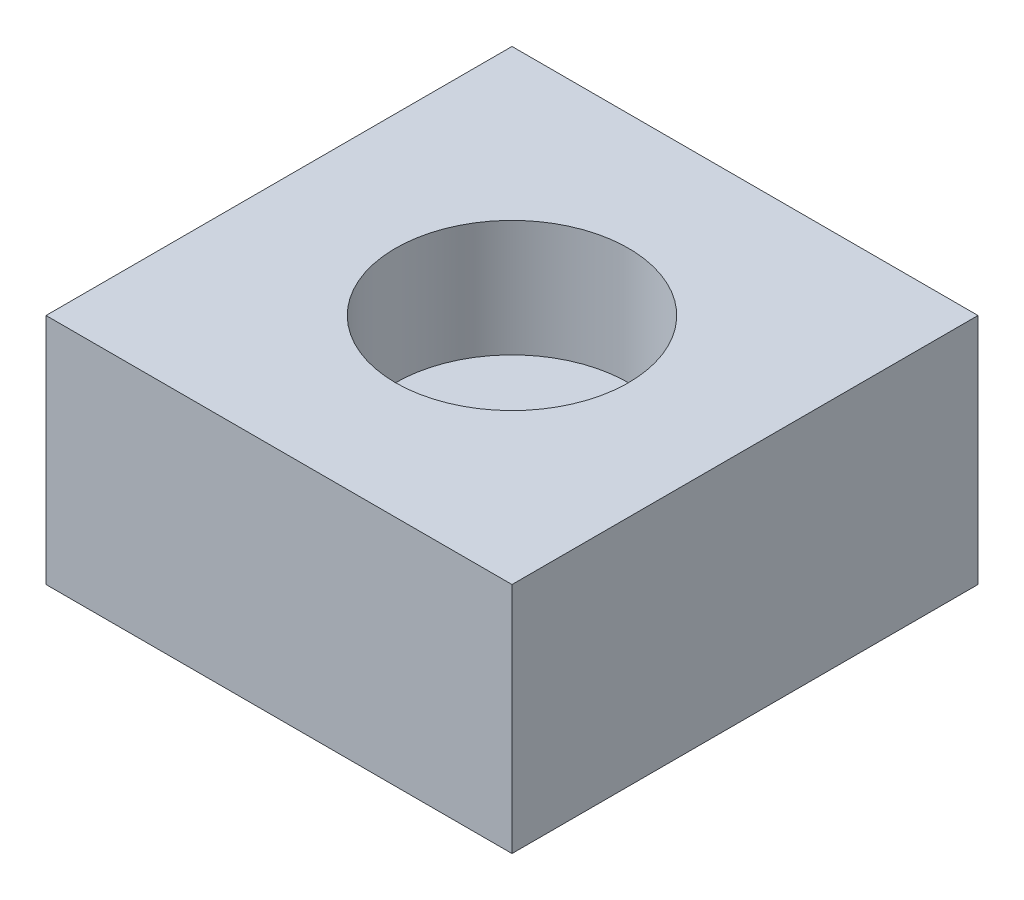
from build123d import *

# Parameters (mm, degrees)
SKETCH1_W           = 20
SKETCH1_H           = 20
BOSS_EXTRUDE1_DEPTH = 10
SKETCH2_R           = 5
CUT_EXTRUDE1_DEPTH  = 5


with BuildPart() as part:
    # Sketch1 → Boss-Extrude1 (new body)
    with BuildSketch(Plane(origin=(0, 0, 0), x_dir=(1, 0, 0), z_dir=(0, 1, 0))):
        with Locations((10, 10)):
            Rectangle(SKETCH1_W, SKETCH1_H)
    extrude(amount=BOSS_EXTRUDE1_DEPTH)

    # Sketch2 → Cut-Extrude1 (cut)
    with BuildSketch(Plane(origin=(0, 10, 0), x_dir=(-1, 0, 0), z_dir=(0, 1, 0))):
        with Locations((-10, -10)):
            Circle(SKETCH2_R)
    extrude(amount=-CUT_EXTRUDE1_DEPTH, mode=Mode.SUBTRACT)


solid = part.part
